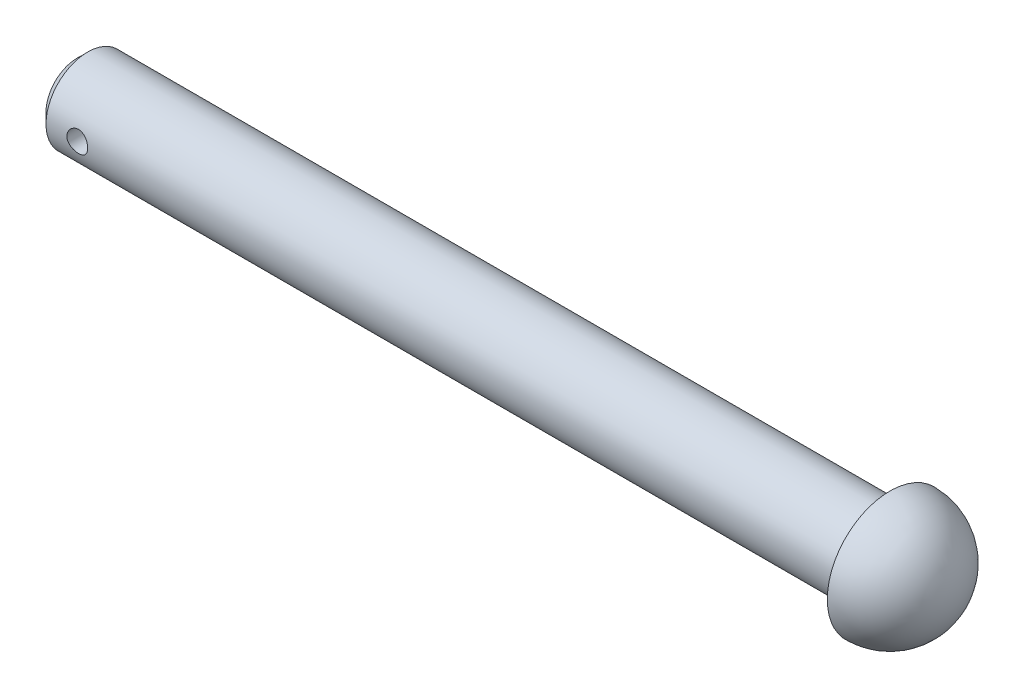
from build123d import *

# Parameters (mm, degrees)
SKETCH2_R          = 0.5
CUT_EXTRUDE1_DEPTH = 5
CHAMFER1_SIZE      = 0.5


with BuildPart() as part:
    # Sketch1 → Revolve1 (revolve)
    with BuildSketch(Plane.XY):
        with BuildLine():
            Line((-11.492242367, 0), (-11.492242367, -2))
            Line((-11.492242367, -2), (27.507757633, -2))
            Line((27.507757633, -2), (27.507757633, -3))
            ThreePointArc((27.507757633, -3), (29.629077976, -2.121320344), (30.507757633, 0))
            Line((30.507757633, 0), (-11.492242367, 0))
        make_face()
    revolve(axis=Axis((-20.421686747, 0, 0), (1, 0, 0)))

    # Sketch2 → Cut-Extrude1 (cut, symmetric)
    with BuildSketch(Plane.XY):
        with Locations((-9.492242367, 0)):
            Circle(SKETCH2_R)
    extrude(amount=CUT_EXTRUDE1_DEPTH, both=True, mode=Mode.SUBTRACT)

    # Chamfer1
    chamfer1_edges = [part.edges().sort_by_distance(p)[0] for p in [
        (-11.492242367, 2, 0),
    ]]
    chamfer(chamfer1_edges, length=CHAMFER1_SIZE)


solid = part.part
